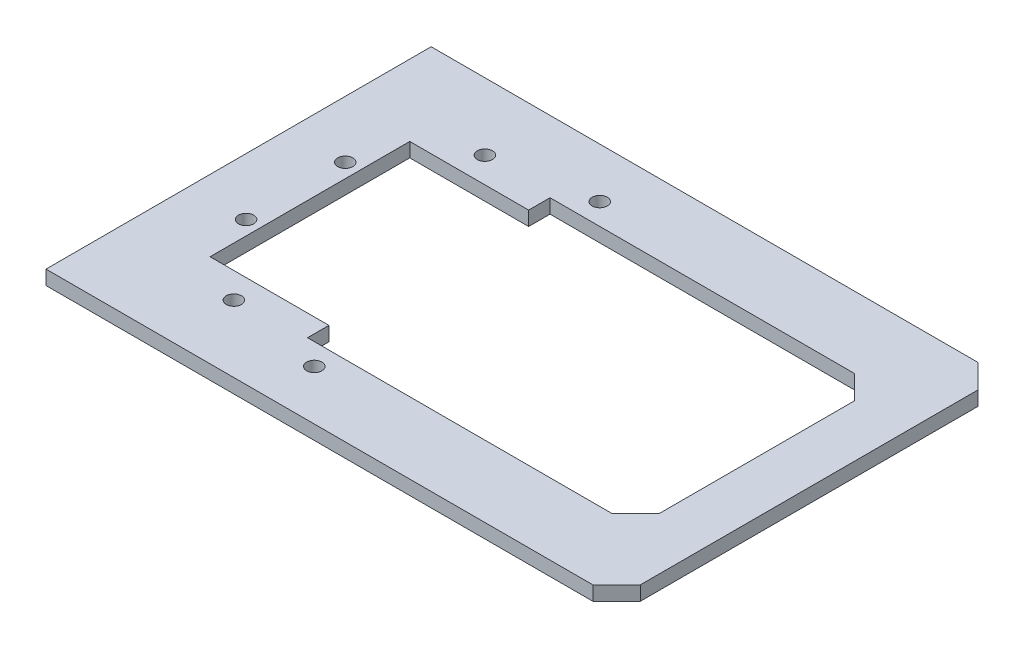
from build123d import *

# Parameters (mm, degrees)
SKETCH1_R           = 1.6
BOSS_EXTRUDE1_DEPTH = 3


with BuildPart() as part:
    # Sketch1 → Boss-Extrude1 (new body)
    with BuildSketch(Plane(origin=(0, 0, 0), x_dir=(1, 0, 0), z_dir=(0, 1, 0))):
        Polygon((86.535317855, -129.61721435), (86.535317855, -119.61721435), (81.535317855, -114.61721435), (-33.464682145, -114.61721435), (-33.464682145, -195.61721435), (81.535317855, -195.61721435), (86.535317855, -190.61721435), (86.535317855, -180.61721435), align=None)
        with Locations((12.469945392, -125.100274039)):
            Circle(SKETCH1_R, mode=Mode.SUBTRACT)
        with Locations((-8.062851064, -128.720760043)):
            Circle(SKETCH1_R, mode=Mode.SUBTRACT)
        with Locations((-21.464682145, -144.692440382)):
            Circle(SKETCH1_R, mode=Mode.SUBTRACT)
        with Locations((-21.464682145, -165.541988319)):
            Circle(SKETCH1_R, mode=Mode.SUBTRACT)
        with Locations((-8.062851064, -181.513668658)):
            Circle(SKETCH1_R, mode=Mode.SUBTRACT)
        with Locations((12.469945392, -185.134154662)):
            Circle(SKETCH1_R, mode=Mode.SUBTRACT)
        Polygon((-18.464682145, -134.11721435), (6.535317855, -134.11721435), (6.535317855, -129.61721435), (70.535317855, -129.61721435), (75.535317855, -134.61721435), (75.535317855, -175.61721435), (70.535317855, -180.61721435), (6.535317855, -180.61721435), (6.535317855, -176.11721435), (-18.464682145, -176.11721435), align=None, mode=Mode.SUBTRACT)
    extrude(amount=BOSS_EXTRUDE1_DEPTH)


solid = part.part
